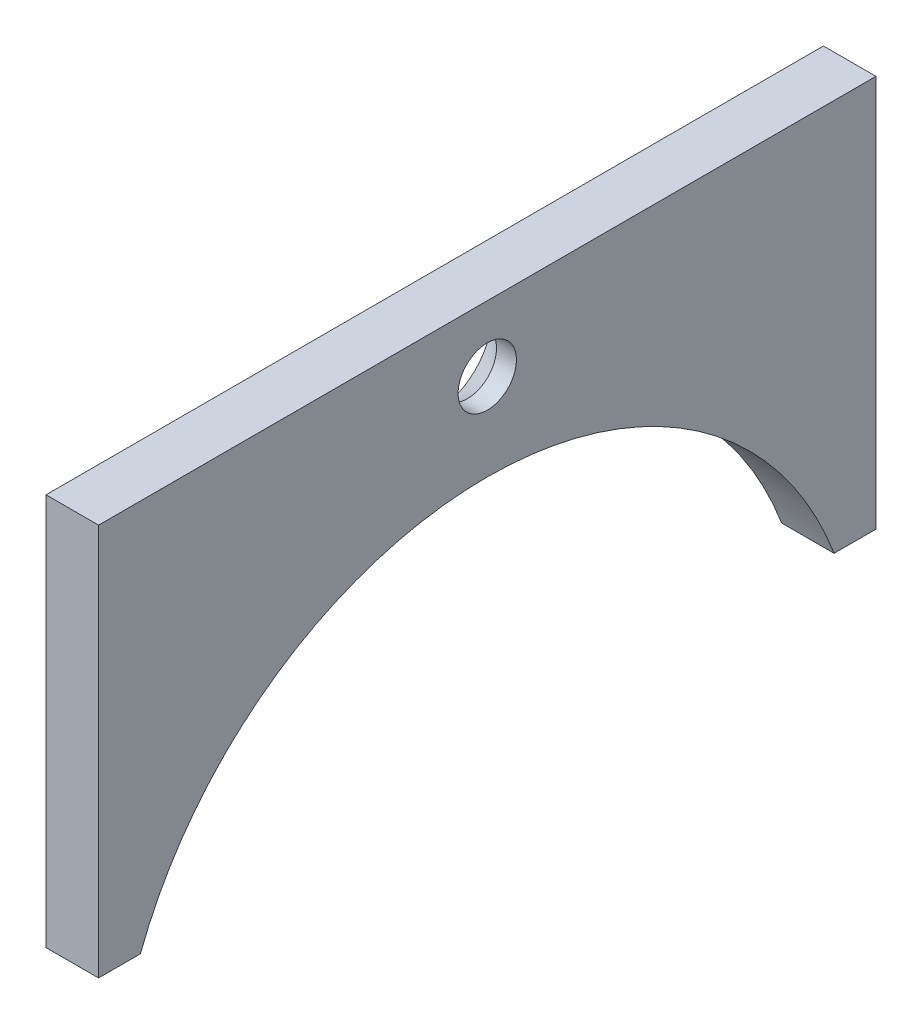
from build123d import *

# Parameters (mm, degrees)
SKETCH1_W                                         = 1.6002
SKETCH1_H                                         = 11.95
BOSS_EXTRUDE1_DEPTH                               = 23.685439
CUT_EXTRUDE1_DEPTH                                = 10
CSK_FOR_0_FLAT_HEAD_SOCKET_CAP_SCREW1_D           = 1.778
CSK_FOR_0_FLAT_HEAD_SOCKET_CAP_SCREW1_DEPTH       = 3
CSK_FOR_0_FLAT_HEAD_SOCKET_CAP_SCREW1_CSINK_D     = 3.5052
CSK_FOR_0_FLAT_HEAD_SOCKET_CAP_SCREW1_CSINK_ANGLE = 82
CSK_FOR_0_FLAT_HEAD_SOCKET_CAP_SCREW1_TIP         = 0.53416509


with BuildPart() as part:
    # Sketch1 → Boss-Extrude1 (new body)
    with BuildSketch(Plane.XY):
        with Locations((-2.5501, 9.975)):
            Rectangle(SKETCH1_W, SKETCH1_H)
    extrude(amount=BOSS_EXTRUDE1_DEPTH)

    # Sketch2 → Cut-Extrude1 (cut)
    with BuildSketch(Plane(origin=(-1.75, 0, 0), x_dir=(0, 0, -1), z_dir=(1, 0, 0))):
        with BuildLine():
            Line((-22.411068255, 4), (-1.27437031, 4))
            ThreePointArc((-1.27437031, 4), (-11.842719282, 11.3), (-22.411068255, 4))
        make_face()
    extrude(amount=-CUT_EXTRUDE1_DEPTH, mode=Mode.SUBTRACT)

    # CSK for #0 Flat Head Socket Cap Screw1
    with Locations(Plane.ZY.offset(3.3502)):
        with Locations((11.842719282, 13.95)):
            CounterSinkHole(CSK_FOR_0_FLAT_HEAD_SOCKET_CAP_SCREW1_D / 2, CSK_FOR_0_FLAT_HEAD_SOCKET_CAP_SCREW1_CSINK_D / 2, depth=CSK_FOR_0_FLAT_HEAD_SOCKET_CAP_SCREW1_DEPTH, counter_sink_angle=CSK_FOR_0_FLAT_HEAD_SOCKET_CAP_SCREW1_CSINK_ANGLE)
            with Locations((0, 0, -(CSK_FOR_0_FLAT_HEAD_SOCKET_CAP_SCREW1_DEPTH + CSK_FOR_0_FLAT_HEAD_SOCKET_CAP_SCREW1_TIP / 2))):  # 118° drill point
                Cone(0, CSK_FOR_0_FLAT_HEAD_SOCKET_CAP_SCREW1_D / 2, CSK_FOR_0_FLAT_HEAD_SOCKET_CAP_SCREW1_TIP, mode=Mode.SUBTRACT)


solid = part.part
